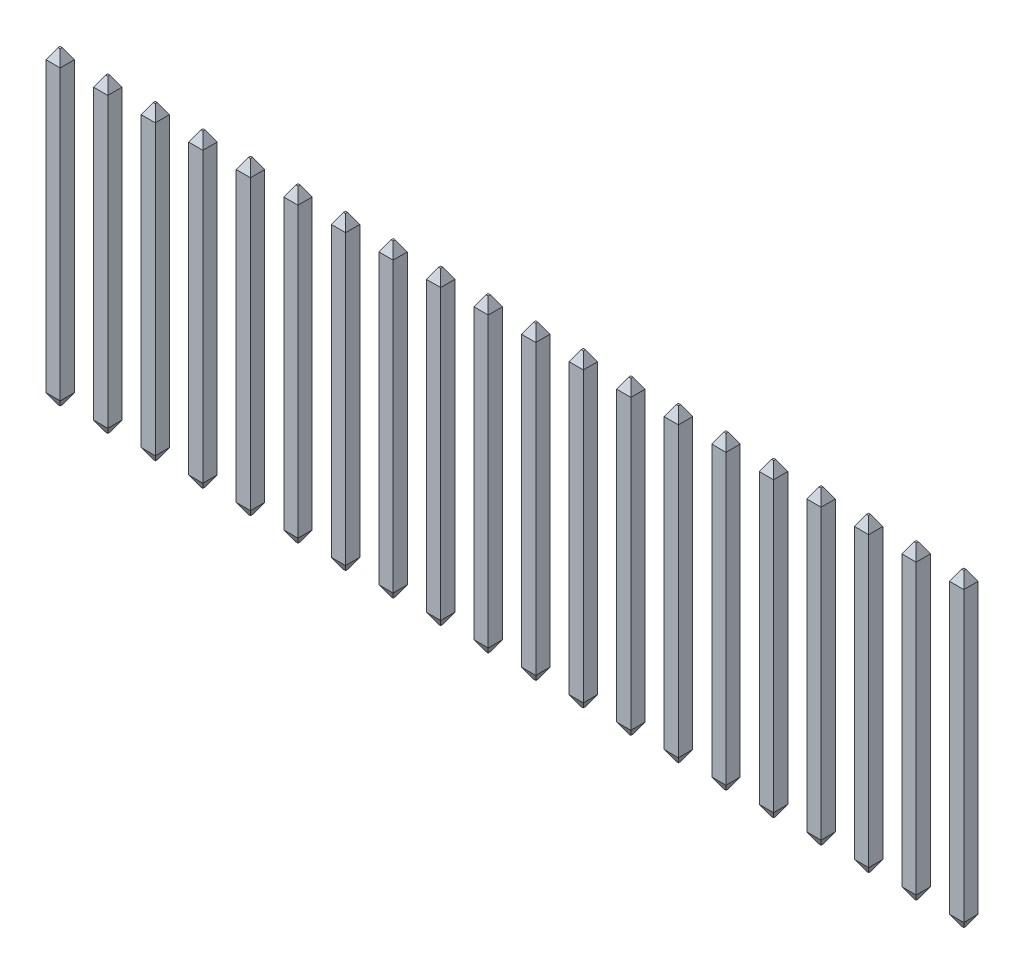
from build123d import *

# Parameters (mm, degrees)
SKETCH1_W                   = 0.38
SKETCH1_H                   = 0.38
BOSS_EXTRUDE1_DEPTH         = 5.72
BOSS_EXTRUDE1_DEPTH_BACK    = 2.54
BOSS_EXTRUDE1_2_DEPTH       = 5.72
BOSS_EXTRUDE1_2_DEPTH_BACK  = 2.54
BOSS_EXTRUDE1_3_DEPTH       = 5.72
BOSS_EXTRUDE1_3_DEPTH_BACK  = 2.54
BOSS_EXTRUDE1_4_DEPTH       = 5.72
BOSS_EXTRUDE1_4_DEPTH_BACK  = 2.54
BOSS_EXTRUDE1_5_DEPTH       = 5.72
BOSS_EXTRUDE1_5_DEPTH_BACK  = 2.54
BOSS_EXTRUDE1_6_DEPTH       = 5.72
BOSS_EXTRUDE1_6_DEPTH_BACK  = 2.54
BOSS_EXTRUDE1_7_DEPTH       = 5.72
BOSS_EXTRUDE1_7_DEPTH_BACK  = 2.54
BOSS_EXTRUDE1_8_DEPTH       = 5.72
BOSS_EXTRUDE1_8_DEPTH_BACK  = 2.54
BOSS_EXTRUDE1_9_DEPTH       = 5.72
BOSS_EXTRUDE1_9_DEPTH_BACK  = 2.54
BOSS_EXTRUDE1_10_DEPTH      = 5.72
BOSS_EXTRUDE1_10_DEPTH_BACK = 2.54
BOSS_EXTRUDE1_11_DEPTH      = 5.72
BOSS_EXTRUDE1_11_DEPTH_BACK = 2.54
BOSS_EXTRUDE1_12_DEPTH      = 5.72
BOSS_EXTRUDE1_12_DEPTH_BACK = 2.54
BOSS_EXTRUDE1_13_DEPTH      = 5.72
BOSS_EXTRUDE1_13_DEPTH_BACK = 2.54
BOSS_EXTRUDE1_14_DEPTH      = 5.72
BOSS_EXTRUDE1_14_DEPTH_BACK = 2.54
BOSS_EXTRUDE1_15_DEPTH      = 5.72
BOSS_EXTRUDE1_15_DEPTH_BACK = 2.54
BOSS_EXTRUDE1_16_DEPTH      = 5.72
BOSS_EXTRUDE1_16_DEPTH_BACK = 2.54
BOSS_EXTRUDE1_17_DEPTH      = 5.72
BOSS_EXTRUDE1_17_DEPTH_BACK = 2.54
BOSS_EXTRUDE1_18_DEPTH      = 5.72
BOSS_EXTRUDE1_18_DEPTH_BACK = 2.54
BOSS_EXTRUDE1_19_DEPTH      = 5.72
BOSS_EXTRUDE1_19_DEPTH_BACK = 2.54
BOSS_EXTRUDE1_20_DEPTH      = 5.72
BOSS_EXTRUDE1_20_DEPTH_BACK = 2.54
SKETCH2_W                   = 24.51
SKETCH2_H                   = 0.38
BOSS_EXTRUDE2_DEPTH         = 1
CHAMFER1_SIZE               = 0.28
CHAMFER1_SIZE2              = 0.161658075
CHAMFER1_PART_2_SIZE        = 0.28
CHAMFER1_PART_2_SIZE2       = 0.161658075
CHAMFER1_PART_3_SIZE        = 0.28
CHAMFER1_PART_3_SIZE2       = 0.161658075
CHAMFER1_PART_4_SIZE        = 0.28
CHAMFER1_PART_4_SIZE2       = 0.161658075
CHAMFER1_PART_5_SIZE        = 0.28
CHAMFER1_PART_5_SIZE2       = 0.161658075
CHAMFER1_PART_6_SIZE        = 0.28
CHAMFER1_PART_6_SIZE2       = 0.161658075
CHAMFER1_PART_7_SIZE        = 0.28
CHAMFER1_PART_7_SIZE2       = 0.161658075
CHAMFER1_PART_8_SIZE        = 0.28
CHAMFER1_PART_8_SIZE2       = 0.161658075
CHAMFER1_PART_9_SIZE        = 0.28
CHAMFER1_PART_9_SIZE2       = 0.161658075
CHAMFER1_PART_10_SIZE       = 0.28
CHAMFER1_PART_10_SIZE2      = 0.161658075
CHAMFER1_PART_11_SIZE       = 0.28
CHAMFER1_PART_11_SIZE2      = 0.161658075
CHAMFER1_PART_12_SIZE       = 0.28
CHAMFER1_PART_12_SIZE2      = 0.161658075
CHAMFER1_PART_13_SIZE       = 0.28
CHAMFER1_PART_13_SIZE2      = 0.161658075
CHAMFER1_PART_14_SIZE       = 0.28
CHAMFER1_PART_14_SIZE2      = 0.161658075
CHAMFER1_PART_15_SIZE       = 0.28
CHAMFER1_PART_15_SIZE2      = 0.161658075
CHAMFER1_PART_16_SIZE       = 0.28
CHAMFER1_PART_16_SIZE2      = 0.161658075
CHAMFER1_PART_17_SIZE       = 0.28
CHAMFER1_PART_17_SIZE2      = 0.161658075
CHAMFER1_PART_18_SIZE       = 0.28
CHAMFER1_PART_18_SIZE2      = 0.161658075
CHAMFER1_PART_19_SIZE       = 0.28
CHAMFER1_PART_19_SIZE2      = 0.161658075
CHAMFER1_PART_20_SIZE       = 0.28
CHAMFER1_PART_20_SIZE2      = 0.161658075
CHAMFER1_PART_21_SIZE       = 0.28
CHAMFER1_PART_21_SIZE2      = 0.161658075
CHAMFER1_PART_22_SIZE       = 0.28
CHAMFER1_PART_22_SIZE2      = 0.161658075
CHAMFER1_PART_23_SIZE       = 0.28
CHAMFER1_PART_23_SIZE2      = 0.161658075
CHAMFER1_PART_24_SIZE       = 0.28
CHAMFER1_PART_24_SIZE2      = 0.161658075
CHAMFER1_PART_25_SIZE       = 0.28
CHAMFER1_PART_25_SIZE2      = 0.161658075
CHAMFER1_PART_26_SIZE       = 0.28
CHAMFER1_PART_26_SIZE2      = 0.161658075
CHAMFER1_PART_27_SIZE       = 0.28
CHAMFER1_PART_27_SIZE2      = 0.161658075
CHAMFER1_PART_28_SIZE       = 0.28
CHAMFER1_PART_28_SIZE2      = 0.161658075
CHAMFER1_PART_29_SIZE       = 0.28
CHAMFER1_PART_29_SIZE2      = 0.161658075
CHAMFER1_PART_30_SIZE       = 0.28
CHAMFER1_PART_30_SIZE2      = 0.161658075
CHAMFER1_PART_31_SIZE       = 0.28
CHAMFER1_PART_31_SIZE2      = 0.161658075
CHAMFER1_PART_32_SIZE       = 0.28
CHAMFER1_PART_32_SIZE2      = 0.161658075
CHAMFER1_PART_33_SIZE       = 0.28
CHAMFER1_PART_33_SIZE2      = 0.161658075
CHAMFER1_PART_34_SIZE       = 0.28
CHAMFER1_PART_34_SIZE2      = 0.161658075
CHAMFER1_PART_35_SIZE       = 0.28
CHAMFER1_PART_35_SIZE2      = 0.161658075
CHAMFER1_PART_36_SIZE       = 0.28
CHAMFER1_PART_36_SIZE2      = 0.161658075
CHAMFER1_PART_37_SIZE       = 0.28
CHAMFER1_PART_37_SIZE2      = 0.161658075
CHAMFER1_PART_38_SIZE       = 0.28
CHAMFER1_PART_38_SIZE2      = 0.161658075
CHAMFER1_PART_39_SIZE       = 0.28
CHAMFER1_PART_39_SIZE2      = 0.161658075
CHAMFER1_PART_40_SIZE       = 0.28
CHAMFER1_PART_40_SIZE2      = 0.161658075
CHAMFER1_PART_41_SIZE       = 0.28
CHAMFER1_PART_41_SIZE2      = 0.161658075
CHAMFER1_PART_42_SIZE       = 0.28
CHAMFER1_PART_42_SIZE2      = 0.161658075
CHAMFER2_SIZE               = 0.28
CHAMFER2_SIZE2              = 0.161658075
CHAMFER2_PART_2_SIZE        = 0.28
CHAMFER2_PART_2_SIZE2       = 0.161658075
CHAMFER2_PART_3_SIZE        = 0.28
CHAMFER2_PART_3_SIZE2       = 0.161658075
CHAMFER2_PART_4_SIZE        = 0.28
CHAMFER2_PART_4_SIZE2       = 0.161658075
CHAMFER2_PART_5_SIZE        = 0.28
CHAMFER2_PART_5_SIZE2       = 0.161658075
CHAMFER2_PART_6_SIZE        = 0.28
CHAMFER2_PART_6_SIZE2       = 0.161658075
CHAMFER2_PART_7_SIZE        = 0.28
CHAMFER2_PART_7_SIZE2       = 0.161658075
CHAMFER2_PART_8_SIZE        = 0.28
CHAMFER2_PART_8_SIZE2       = 0.161658075
CHAMFER2_PART_9_SIZE        = 0.28
CHAMFER2_PART_9_SIZE2       = 0.161658075
CHAMFER2_PART_10_SIZE       = 0.28
CHAMFER2_PART_10_SIZE2      = 0.161658075
CHAMFER2_PART_11_SIZE       = 0.28
CHAMFER2_PART_11_SIZE2      = 0.161658075
CHAMFER2_PART_12_SIZE       = 0.28
CHAMFER2_PART_12_SIZE2      = 0.161658075
CHAMFER2_PART_13_SIZE       = 0.28
CHAMFER2_PART_13_SIZE2      = 0.161658075
CHAMFER2_PART_14_SIZE       = 0.28
CHAMFER2_PART_14_SIZE2      = 0.161658075
CHAMFER2_PART_15_SIZE       = 0.28
CHAMFER2_PART_15_SIZE2      = 0.161658075
CHAMFER2_PART_16_SIZE       = 0.28
CHAMFER2_PART_16_SIZE2      = 0.161658075
CHAMFER2_PART_17_SIZE       = 0.28
CHAMFER2_PART_17_SIZE2      = 0.161658075
CHAMFER2_PART_18_SIZE       = 0.28
CHAMFER2_PART_18_SIZE2      = 0.161658075
CHAMFER2_PART_19_SIZE       = 0.28
CHAMFER2_PART_19_SIZE2      = 0.161658075
CHAMFER2_PART_20_SIZE       = 0.28
CHAMFER2_PART_20_SIZE2      = 0.161658075
CHAMFER2_PART_21_SIZE       = 0.28
CHAMFER2_PART_21_SIZE2      = 0.161658075
CHAMFER2_PART_22_SIZE       = 0.28
CHAMFER2_PART_22_SIZE2      = 0.161658075
CHAMFER2_PART_23_SIZE       = 0.28
CHAMFER2_PART_23_SIZE2      = 0.161658075
CHAMFER2_PART_24_SIZE       = 0.28
CHAMFER2_PART_24_SIZE2      = 0.161658075
CHAMFER2_PART_25_SIZE       = 0.28
CHAMFER2_PART_25_SIZE2      = 0.161658075
CHAMFER2_PART_26_SIZE       = 0.28
CHAMFER2_PART_26_SIZE2      = 0.161658075
CHAMFER2_PART_27_SIZE       = 0.28
CHAMFER2_PART_27_SIZE2      = 0.161658075
CHAMFER2_PART_28_SIZE       = 0.28
CHAMFER2_PART_28_SIZE2      = 0.161658075
CHAMFER2_PART_29_SIZE       = 0.28
CHAMFER2_PART_29_SIZE2      = 0.161658075
CHAMFER2_PART_30_SIZE       = 0.28
CHAMFER2_PART_30_SIZE2      = 0.161658075
CHAMFER2_PART_31_SIZE       = 0.28
CHAMFER2_PART_31_SIZE2      = 0.161658075
CHAMFER2_PART_32_SIZE       = 0.28
CHAMFER2_PART_32_SIZE2      = 0.161658075
CHAMFER2_PART_33_SIZE       = 0.28
CHAMFER2_PART_33_SIZE2      = 0.161658075
CHAMFER2_PART_34_SIZE       = 0.28
CHAMFER2_PART_34_SIZE2      = 0.161658075
CHAMFER2_PART_35_SIZE       = 0.28
CHAMFER2_PART_35_SIZE2      = 0.161658075
CHAMFER2_PART_36_SIZE       = 0.28
CHAMFER2_PART_36_SIZE2      = 0.161658075
CHAMFER2_PART_37_SIZE       = 0.28
CHAMFER2_PART_37_SIZE2      = 0.161658075
CHAMFER2_PART_38_SIZE       = 0.28
CHAMFER2_PART_38_SIZE2      = 0.161658075
CHAMFER2_PART_39_SIZE       = 0.28
CHAMFER2_PART_39_SIZE2      = 0.161658075
CHAMFER2_PART_40_SIZE       = 0.28
CHAMFER2_PART_40_SIZE2      = 0.161658075
CHAMFER2_PART_41_SIZE       = 0.28
CHAMFER2_PART_41_SIZE2      = 0.161658075
CHAMFER2_PART_42_SIZE       = 0.28
CHAMFER2_PART_42_SIZE2      = 0.161658075
SKETCH3_W                   = 0.89
SKETCH3_H                   = 0.38
CUT_EXTRUDE1_DEPTH          = 1


with BuildPart() as part:
    # Sketch1 → Boss-Extrude1 (new body, two sides)
    with BuildSketch(Plane(origin=(0, 0, 0), x_dir=(1, 0, 0), z_dir=(0, 1, 0))) as boss_extrude1_sk:
        with Locations((-10.795, 0)):
            Rectangle(SKETCH1_W, SKETCH1_H)
    extrude(amount=BOSS_EXTRUDE1_DEPTH)
    extrude(boss_extrude1_sk.sketch, amount=-BOSS_EXTRUDE1_DEPTH_BACK)



with BuildPart() as body_2:
    # Sketch1 → Boss-Extrude1 2 (new body, two sides)
    with BuildSketch(Plane(origin=(0, 0, 0), x_dir=(1, 0, 0), z_dir=(0, 1, 0))) as boss_extrude1_2_sk:
        with Locations((-12.065, 0)):
            Rectangle(SKETCH1_W, SKETCH1_H)
    extrude(amount=BOSS_EXTRUDE1_2_DEPTH)
    extrude(boss_extrude1_2_sk.sketch, amount=-BOSS_EXTRUDE1_2_DEPTH_BACK)


with BuildPart() as body_3:
    # Sketch1 → Boss-Extrude1 3 (new body, two sides)
    with BuildSketch(Plane(origin=(0, 0, 0), x_dir=(1, 0, 0), z_dir=(0, 1, 0))) as boss_extrude1_3_sk:
        with Locations((-9.525, 0)):
            Rectangle(SKETCH1_W, SKETCH1_H)
    extrude(amount=BOSS_EXTRUDE1_3_DEPTH)
    extrude(boss_extrude1_3_sk.sketch, amount=-BOSS_EXTRUDE1_3_DEPTH_BACK)


with BuildPart() as body_4:
    # Sketch1 → Boss-Extrude1 4 (new body, two sides)
    with BuildSketch(Plane(origin=(0, 0, 0), x_dir=(1, 0, 0), z_dir=(0, 1, 0))) as boss_extrude1_4_sk:
        with Locations((-8.255, 0)):
            Rectangle(SKETCH1_W, SKETCH1_H)
    extrude(amount=BOSS_EXTRUDE1_4_DEPTH)
    extrude(boss_extrude1_4_sk.sketch, amount=-BOSS_EXTRUDE1_4_DEPTH_BACK)


with BuildPart() as body_5:
    # Sketch1 → Boss-Extrude1 5 (new body, two sides)
    with BuildSketch(Plane(origin=(0, 0, 0), x_dir=(1, 0, 0), z_dir=(0, 1, 0))) as boss_extrude1_5_sk:
        with Locations((-6.985, 0)):
            Rectangle(SKETCH1_W, SKETCH1_H)
    extrude(amount=BOSS_EXTRUDE1_5_DEPTH)
    extrude(boss_extrude1_5_sk.sketch, amount=-BOSS_EXTRUDE1_5_DEPTH_BACK)


with BuildPart() as body_6:
    # Sketch1 → Boss-Extrude1 6 (new body, two sides)
    with BuildSketch(Plane(origin=(0, 0, 0), x_dir=(1, 0, 0), z_dir=(0, 1, 0))) as boss_extrude1_6_sk:
        with Locations((-5.715, 0)):
            Rectangle(SKETCH1_W, SKETCH1_H)
    extrude(amount=BOSS_EXTRUDE1_6_DEPTH)
    extrude(boss_extrude1_6_sk.sketch, amount=-BOSS_EXTRUDE1_6_DEPTH_BACK)


with BuildPart() as body_7:
    # Sketch1 → Boss-Extrude1 7 (new body, two sides)
    with BuildSketch(Plane(origin=(0, 0, 0), x_dir=(1, 0, 0), z_dir=(0, 1, 0))) as boss_extrude1_7_sk:
        with Locations((-4.445, 0)):
            Rectangle(SKETCH1_W, SKETCH1_H)
    extrude(amount=BOSS_EXTRUDE1_7_DEPTH)
    extrude(boss_extrude1_7_sk.sketch, amount=-BOSS_EXTRUDE1_7_DEPTH_BACK)


with BuildPart() as body_8:
    # Sketch1 → Boss-Extrude1 8 (new body, two sides)
    with BuildSketch(Plane(origin=(0, 0, 0), x_dir=(1, 0, 0), z_dir=(0, 1, 0))) as boss_extrude1_8_sk:
        with Locations((-3.175, 0)):
            Rectangle(SKETCH1_W, SKETCH1_H)
    extrude(amount=BOSS_EXTRUDE1_8_DEPTH)
    extrude(boss_extrude1_8_sk.sketch, amount=-BOSS_EXTRUDE1_8_DEPTH_BACK)


with BuildPart() as body_9:
    # Sketch1 → Boss-Extrude1 9 (new body, two sides)
    with BuildSketch(Plane(origin=(0, 0, 0), x_dir=(1, 0, 0), z_dir=(0, 1, 0))) as boss_extrude1_9_sk:
        with Locations((-1.905, 0)):
            Rectangle(SKETCH1_W, SKETCH1_H)
    extrude(amount=BOSS_EXTRUDE1_9_DEPTH)
    extrude(boss_extrude1_9_sk.sketch, amount=-BOSS_EXTRUDE1_9_DEPTH_BACK)


with BuildPart() as body_10:
    # Sketch1 → Boss-Extrude1 10 (new body, two sides)
    with BuildSketch(Plane(origin=(0, 0, 0), x_dir=(1, 0, 0), z_dir=(0, 1, 0))) as boss_extrude1_10_sk:
        with Locations((-0.635, 0)):
            Rectangle(SKETCH1_W, SKETCH1_H)
    extrude(amount=BOSS_EXTRUDE1_10_DEPTH)
    extrude(boss_extrude1_10_sk.sketch, amount=-BOSS_EXTRUDE1_10_DEPTH_BACK)


with BuildPart() as body_11:
    # Sketch1 → Boss-Extrude1 11 (new body, two sides)
    with BuildSketch(Plane(origin=(0, 0, 0), x_dir=(1, 0, 0), z_dir=(0, 1, 0))) as boss_extrude1_11_sk:
        with Locations((0.635, 0)):
            Rectangle(SKETCH1_W, SKETCH1_H)
    extrude(amount=BOSS_EXTRUDE1_11_DEPTH)
    extrude(boss_extrude1_11_sk.sketch, amount=-BOSS_EXTRUDE1_11_DEPTH_BACK)


with BuildPart() as body_12:
    # Sketch1 → Boss-Extrude1 12 (new body, two sides)
    with BuildSketch(Plane(origin=(0, 0, 0), x_dir=(1, 0, 0), z_dir=(0, 1, 0))) as boss_extrude1_12_sk:
        with Locations((1.905, 0)):
            Rectangle(SKETCH1_W, SKETCH1_H)
    extrude(amount=BOSS_EXTRUDE1_12_DEPTH)
    extrude(boss_extrude1_12_sk.sketch, amount=-BOSS_EXTRUDE1_12_DEPTH_BACK)


with BuildPart() as body_13:
    # Sketch1 → Boss-Extrude1 13 (new body, two sides)
    with BuildSketch(Plane(origin=(0, 0, 0), x_dir=(1, 0, 0), z_dir=(0, 1, 0))) as boss_extrude1_13_sk:
        with Locations((3.175, 0)):
            Rectangle(SKETCH1_W, SKETCH1_H)
    extrude(amount=BOSS_EXTRUDE1_13_DEPTH)
    extrude(boss_extrude1_13_sk.sketch, amount=-BOSS_EXTRUDE1_13_DEPTH_BACK)


with BuildPart() as body_14:
    # Sketch1 → Boss-Extrude1 14 (new body, two sides)
    with BuildSketch(Plane(origin=(0, 0, 0), x_dir=(1, 0, 0), z_dir=(0, 1, 0))) as boss_extrude1_14_sk:
        with Locations((4.445, 0)):
            Rectangle(SKETCH1_W, SKETCH1_H)
    extrude(amount=BOSS_EXTRUDE1_14_DEPTH)
    extrude(boss_extrude1_14_sk.sketch, amount=-BOSS_EXTRUDE1_14_DEPTH_BACK)


with BuildPart() as body_15:
    # Sketch1 → Boss-Extrude1 15 (new body, two sides)
    with BuildSketch(Plane(origin=(0, 0, 0), x_dir=(1, 0, 0), z_dir=(0, 1, 0))) as boss_extrude1_15_sk:
        with Locations((5.715, 0)):
            Rectangle(SKETCH1_W, SKETCH1_H)
    extrude(amount=BOSS_EXTRUDE1_15_DEPTH)
    extrude(boss_extrude1_15_sk.sketch, amount=-BOSS_EXTRUDE1_15_DEPTH_BACK)


with BuildPart() as body_16:
    # Sketch1 → Boss-Extrude1 16 (new body, two sides)
    with BuildSketch(Plane(origin=(0, 0, 0), x_dir=(1, 0, 0), z_dir=(0, 1, 0))) as boss_extrude1_16_sk:
        with Locations((6.985, 0)):
            Rectangle(SKETCH1_W, SKETCH1_H)
    extrude(amount=BOSS_EXTRUDE1_16_DEPTH)
    extrude(boss_extrude1_16_sk.sketch, amount=-BOSS_EXTRUDE1_16_DEPTH_BACK)


with BuildPart() as body_17:
    # Sketch1 → Boss-Extrude1 17 (new body, two sides)
    with BuildSketch(Plane(origin=(0, 0, 0), x_dir=(1, 0, 0), z_dir=(0, 1, 0))) as boss_extrude1_17_sk:
        with Locations((8.255, 0)):
            Rectangle(SKETCH1_W, SKETCH1_H)
    extrude(amount=BOSS_EXTRUDE1_17_DEPTH)
    extrude(boss_extrude1_17_sk.sketch, amount=-BOSS_EXTRUDE1_17_DEPTH_BACK)


with BuildPart() as body_18:
    # Sketch1 → Boss-Extrude1 18 (new body, two sides)
    with BuildSketch(Plane(origin=(0, 0, 0), x_dir=(1, 0, 0), z_dir=(0, 1, 0))) as boss_extrude1_18_sk:
        with Locations((9.525, 0)):
            Rectangle(SKETCH1_W, SKETCH1_H)
    extrude(amount=BOSS_EXTRUDE1_18_DEPTH)
    extrude(boss_extrude1_18_sk.sketch, amount=-BOSS_EXTRUDE1_18_DEPTH_BACK)


with BuildPart() as body_19:
    # Sketch1 → Boss-Extrude1 19 (new body, two sides)
    with BuildSketch(Plane(origin=(0, 0, 0), x_dir=(1, 0, 0), z_dir=(0, 1, 0))) as boss_extrude1_19_sk:
        with Locations((10.795, 0)):
            Rectangle(SKETCH1_W, SKETCH1_H)
    extrude(amount=BOSS_EXTRUDE1_19_DEPTH)
    extrude(boss_extrude1_19_sk.sketch, amount=-BOSS_EXTRUDE1_19_DEPTH_BACK)


with BuildPart() as body_20:
    # Sketch1 → Boss-Extrude1 20 (new body, two sides)
    with BuildSketch(Plane(origin=(0, 0, 0), x_dir=(1, 0, 0), z_dir=(0, 1, 0))) as boss_extrude1_20_sk:
        with Locations((12.065, 0)):
            Rectangle(SKETCH1_W, SKETCH1_H)
    extrude(amount=BOSS_EXTRUDE1_20_DEPTH)
    extrude(boss_extrude1_20_sk.sketch, amount=-BOSS_EXTRUDE1_20_DEPTH_BACK)


with BuildPart() as part_1:
    add(part.part)

    add(body_2.part)  # Boss-Extrude2 merges body 2

    add(body_3.part)  # Boss-Extrude2 merges body 3

    add(body_4.part)  # Boss-Extrude2 merges body 4

    add(body_5.part)  # Boss-Extrude2 merges body 5

    add(body_6.part)  # Boss-Extrude2 merges body 6

    add(body_7.part)  # Boss-Extrude2 merges body 7

    add(body_8.part)  # Boss-Extrude2 merges body 8

    add(body_9.part)  # Boss-Extrude2 merges body 9

    add(body_10.part)  # Boss-Extrude2 merges body 10

    add(body_11.part)  # Boss-Extrude2 merges body 11

    add(body_12.part)  # Boss-Extrude2 merges body 12

    add(body_13.part)  # Boss-Extrude2 merges body 13

    add(body_14.part)  # Boss-Extrude2 merges body 14

    add(body_15.part)  # Boss-Extrude2 merges body 15

    add(body_16.part)  # Boss-Extrude2 merges body 16

    add(body_17.part)  # Boss-Extrude2 merges body 17

    add(body_18.part)  # Boss-Extrude2 merges body 18

    add(body_19.part)  # Boss-Extrude2 merges body 19

    add(body_20.part)  # Boss-Extrude2 merges body 20
    # Sketch2 → Boss-Extrude2 (add)
    with BuildSketch(Plane(origin=(0, 0, 0), x_dir=(1, 0, 0), z_dir=(0, 1, 0))):
        Rectangle(SKETCH2_W, SKETCH2_H)
    extrude(amount=BOSS_EXTRUDE2_DEPTH)

    # Chamfer1
    chamfer1_edges = [part_1.edges().sort_by_distance(p)[0] for p in [
        (-8.255, 5.72, -0.19),
        (-6.985, 5.72, -0.19),
        (-12.065, 5.72, -0.19),
        (-5.715, 5.72, -0.19),
        (-4.445, 5.72, -0.19),
        (-3.175, 5.72, -0.19),
        (-1.905, 5.72, -0.19),
        (-0.635, 5.72, -0.19),
        (0.635, 5.72, -0.19),
        (1.905, 5.72, -0.19),
        (3.175, 5.72, -0.19),
        (4.445, 5.72, -0.19),
        (5.715, 5.72, -0.19),
        (6.985, 5.72, -0.19),
        (8.255, 5.72, -0.19),
        (9.525, 5.72, -0.19),
        (10.795, 5.72, -0.19),
        (12.065, 5.72, -0.19),
        (-10.795, 5.72, -0.19),
        (-9.525, 5.72, -0.19),
    ]]
    chamfer1_side = [part_1.faces().sort_by_distance(p)[0] for p in [
        (12.065, 5.461355901, -0.19),
    ]]
    chamfer(chamfer1_edges, length=CHAMFER1_SIZE, length2=CHAMFER1_SIZE2, reference=chamfer1_side[0])

    # Chamfer1 part 2
    chamfer1_part_2_edges = [part_1.edges().sort_by_distance(p)[0] for p in [
        (-8.445, 5.72, 0),
    ]]
    chamfer1_part_2_side = [part_1.faces().sort_by_distance(p)[0] for p in [
        (-8.445, 3.36, 0),
    ]]
    chamfer(chamfer1_part_2_edges, length=CHAMFER1_PART_2_SIZE, length2=CHAMFER1_PART_2_SIZE2, reference=chamfer1_part_2_side[0])

    # Chamfer1 part 3
    chamfer1_part_3_edges = [part_1.edges().sort_by_distance(p)[0] for p in [
        (-8.255, 5.72, 0.19),
        (-6.985, 5.72, 0.19),
        (-12.065, 5.72, 0.19),
        (-5.715, 5.72, 0.19),
        (-4.445, 5.72, 0.19),
        (-3.175, 5.72, 0.19),
        (-1.905, 5.72, 0.19),
        (-0.635, 5.72, 0.19),
        (0.635, 5.72, 0.19),
        (1.905, 5.72, 0.19),
        (3.175, 5.72, 0.19),
        (4.445, 5.72, 0.19),
        (5.715, 5.72, 0.19),
        (6.985, 5.72, 0.19),
        (8.255, 5.72, 0.19),
        (9.525, 5.72, 0.19),
        (10.795, 5.72, 0.19),
        (12.065, 5.72, 0.19),
        (-10.795, 5.72, 0.19),
        (-9.525, 5.72, 0.19),
    ]]
    chamfer1_part_3_side = [part_1.faces().sort_by_distance(p)[0] for p in [
        (12.133644099, 3.36, 0.19),
    ]]
    chamfer(chamfer1_part_3_edges, length=CHAMFER1_PART_3_SIZE, length2=CHAMFER1_PART_3_SIZE2, reference=chamfer1_part_3_side[0])

    # Chamfer1 part 4
    chamfer1_part_4_edges = [part_1.edges().sort_by_distance(p)[0] for p in [
        (-8.065, 5.72, 0),
    ]]
    chamfer1_part_4_side = [part_1.faces().sort_by_distance(p)[0] for p in [
        (-8.065, 3.36, 0),
    ]]
    chamfer(chamfer1_part_4_edges, length=CHAMFER1_PART_4_SIZE, length2=CHAMFER1_PART_4_SIZE2, reference=chamfer1_part_4_side[0])

    # Chamfer1 part 5
    chamfer1_part_5_edges = [part_1.edges().sort_by_distance(p)[0] for p in [
        (-7.175, 5.72, 0),
    ]]
    chamfer1_part_5_side = [part_1.faces().sort_by_distance(p)[0] for p in [
        (-7.175, 3.36, 0),
    ]]
    chamfer(chamfer1_part_5_edges, length=CHAMFER1_PART_5_SIZE, length2=CHAMFER1_PART_5_SIZE2, reference=chamfer1_part_5_side[0])

    # Chamfer1 part 6
    chamfer1_part_6_edges = [part_1.edges().sort_by_distance(p)[0] for p in [
        (-6.795, 5.72, 0),
    ]]
    chamfer1_part_6_side = [part_1.faces().sort_by_distance(p)[0] for p in [
        (-6.795, 3.36, 0),
    ]]
    chamfer(chamfer1_part_6_edges, length=CHAMFER1_PART_6_SIZE, length2=CHAMFER1_PART_6_SIZE2, reference=chamfer1_part_6_side[0])

    # Chamfer1 part 7
    chamfer1_part_7_edges = [part_1.edges().sort_by_distance(p)[0] for p in [
        (-11.875, 5.72, 0),
    ]]
    chamfer1_part_7_side = [part_1.faces().sort_by_distance(p)[0] for p in [
        (-11.875, 3.36, 0),
    ]]
    chamfer(chamfer1_part_7_edges, length=CHAMFER1_PART_7_SIZE, length2=CHAMFER1_PART_7_SIZE2, reference=chamfer1_part_7_side[0])

    # Chamfer1 part 8
    chamfer1_part_8_edges = [part_1.edges().sort_by_distance(p)[0] for p in [
        (-12.255, 5.72, 0),
    ]]
    chamfer1_part_8_side = [part_1.faces().sort_by_distance(p)[0] for p in [
        (-12.255, 1.59, 0),
    ]]
    chamfer(chamfer1_part_8_edges, length=CHAMFER1_PART_8_SIZE, length2=CHAMFER1_PART_8_SIZE2, reference=chamfer1_part_8_side[0])

    # Chamfer1 part 9
    chamfer1_part_9_edges = [part_1.edges().sort_by_distance(p)[0] for p in [
        (-5.905, 5.72, 0),
    ]]
    chamfer1_part_9_side = [part_1.faces().sort_by_distance(p)[0] for p in [
        (-5.905, 3.36, 0),
    ]]
    chamfer(chamfer1_part_9_edges, length=CHAMFER1_PART_9_SIZE, length2=CHAMFER1_PART_9_SIZE2, reference=chamfer1_part_9_side[0])

    # Chamfer1 part 10
    chamfer1_part_10_edges = [part_1.edges().sort_by_distance(p)[0] for p in [
        (-5.525, 5.72, 0),
    ]]
    chamfer1_part_10_side = [part_1.faces().sort_by_distance(p)[0] for p in [
        (-5.525, 3.36, 0),
    ]]
    chamfer(chamfer1_part_10_edges, length=CHAMFER1_PART_10_SIZE, length2=CHAMFER1_PART_10_SIZE2, reference=chamfer1_part_10_side[0])

    # Chamfer1 part 11
    chamfer1_part_11_edges = [part_1.edges().sort_by_distance(p)[0] for p in [
        (-4.635, 5.72, 0),
    ]]
    chamfer1_part_11_side = [part_1.faces().sort_by_distance(p)[0] for p in [
        (-4.635, 3.36, 0),
    ]]
    chamfer(chamfer1_part_11_edges, length=CHAMFER1_PART_11_SIZE, length2=CHAMFER1_PART_11_SIZE2, reference=chamfer1_part_11_side[0])

    # Chamfer1 part 12
    chamfer1_part_12_edges = [part_1.edges().sort_by_distance(p)[0] for p in [
        (-4.255, 5.72, 0),
    ]]
    chamfer1_part_12_side = [part_1.faces().sort_by_distance(p)[0] for p in [
        (-4.255, 3.36, 0),
    ]]
    chamfer(chamfer1_part_12_edges, length=CHAMFER1_PART_12_SIZE, length2=CHAMFER1_PART_12_SIZE2, reference=chamfer1_part_12_side[0])

    # Chamfer1 part 13
    chamfer1_part_13_edges = [part_1.edges().sort_by_distance(p)[0] for p in [
        (-3.365, 5.72, 0),
    ]]
    chamfer1_part_13_side = [part_1.faces().sort_by_distance(p)[0] for p in [
        (-3.365, 3.36, 0),
    ]]
    chamfer(chamfer1_part_13_edges, length=CHAMFER1_PART_13_SIZE, length2=CHAMFER1_PART_13_SIZE2, reference=chamfer1_part_13_side[0])

    # Chamfer1 part 14
    chamfer1_part_14_edges = [part_1.edges().sort_by_distance(p)[0] for p in [
        (-2.985, 5.72, 0),
    ]]
    chamfer1_part_14_side = [part_1.faces().sort_by_distance(p)[0] for p in [
        (-2.985, 3.36, 0),
    ]]
    chamfer(chamfer1_part_14_edges, length=CHAMFER1_PART_14_SIZE, length2=CHAMFER1_PART_14_SIZE2, reference=chamfer1_part_14_side[0])

    # Chamfer1 part 15
    chamfer1_part_15_edges = [part_1.edges().sort_by_distance(p)[0] for p in [
        (-2.095, 5.72, 0),
    ]]
    chamfer1_part_15_side = [part_1.faces().sort_by_distance(p)[0] for p in [
        (-2.095, 3.36, 0),
    ]]
    chamfer(chamfer1_part_15_edges, length=CHAMFER1_PART_15_SIZE, length2=CHAMFER1_PART_15_SIZE2, reference=chamfer1_part_15_side[0])

    # Chamfer1 part 16
    chamfer1_part_16_edges = [part_1.edges().sort_by_distance(p)[0] for p in [
        (-1.715, 5.72, 0),
    ]]
    chamfer1_part_16_side = [part_1.faces().sort_by_distance(p)[0] for p in [
        (-1.715, 3.36, 0),
    ]]
    chamfer(chamfer1_part_16_edges, length=CHAMFER1_PART_16_SIZE, length2=CHAMFER1_PART_16_SIZE2, reference=chamfer1_part_16_side[0])

    # Chamfer1 part 17
    chamfer1_part_17_edges = [part_1.edges().sort_by_distance(p)[0] for p in [
        (-0.825, 5.72, 0),
    ]]
    chamfer1_part_17_side = [part_1.faces().sort_by_distance(p)[0] for p in [
        (-0.825, 3.36, 0),
    ]]
    chamfer(chamfer1_part_17_edges, length=CHAMFER1_PART_17_SIZE, length2=CHAMFER1_PART_17_SIZE2, reference=chamfer1_part_17_side[0])

    # Chamfer1 part 18
    chamfer1_part_18_edges = [part_1.edges().sort_by_distance(p)[0] for p in [
        (-0.445, 5.72, 0),
    ]]
    chamfer1_part_18_side = [part_1.faces().sort_by_distance(p)[0] for p in [
        (-0.445, 3.36, 0),
    ]]
    chamfer(chamfer1_part_18_edges, length=CHAMFER1_PART_18_SIZE, length2=CHAMFER1_PART_18_SIZE2, reference=chamfer1_part_18_side[0])

    # Chamfer1 part 19
    chamfer1_part_19_edges = [part_1.edges().sort_by_distance(p)[0] for p in [
        (0.445, 5.72, 0),
    ]]
    chamfer1_part_19_side = [part_1.faces().sort_by_distance(p)[0] for p in [
        (0.445, 3.36, 0),
    ]]
    chamfer(chamfer1_part_19_edges, length=CHAMFER1_PART_19_SIZE, length2=CHAMFER1_PART_19_SIZE2, reference=chamfer1_part_19_side[0])

    # Chamfer1 part 20
    chamfer1_part_20_edges = [part_1.edges().sort_by_distance(p)[0] for p in [
        (0.825, 5.72, 0),
    ]]
    chamfer1_part_20_side = [part_1.faces().sort_by_distance(p)[0] for p in [
        (0.825, 3.36, 0),
    ]]
    chamfer(chamfer1_part_20_edges, length=CHAMFER1_PART_20_SIZE, length2=CHAMFER1_PART_20_SIZE2, reference=chamfer1_part_20_side[0])

    # Chamfer1 part 21
    chamfer1_part_21_edges = [part_1.edges().sort_by_distance(p)[0] for p in [
        (1.715, 5.72, 0),
    ]]
    chamfer1_part_21_side = [part_1.faces().sort_by_distance(p)[0] for p in [
        (1.715, 3.36, 0),
    ]]
    chamfer(chamfer1_part_21_edges, length=CHAMFER1_PART_21_SIZE, length2=CHAMFER1_PART_21_SIZE2, reference=chamfer1_part_21_side[0])

    # Chamfer1 part 22
    chamfer1_part_22_edges = [part_1.edges().sort_by_distance(p)[0] for p in [
        (2.095, 5.72, 0),
    ]]
    chamfer1_part_22_side = [part_1.faces().sort_by_distance(p)[0] for p in [
        (2.095, 3.36, 0),
    ]]
    chamfer(chamfer1_part_22_edges, length=CHAMFER1_PART_22_SIZE, length2=CHAMFER1_PART_22_SIZE2, reference=chamfer1_part_22_side[0])

    # Chamfer1 part 23
    chamfer1_part_23_edges = [part_1.edges().sort_by_distance(p)[0] for p in [
        (2.985, 5.72, 0),
    ]]
    chamfer1_part_23_side = [part_1.faces().sort_by_distance(p)[0] for p in [
        (2.985, 3.36, 0),
    ]]
    chamfer(chamfer1_part_23_edges, length=CHAMFER1_PART_23_SIZE, length2=CHAMFER1_PART_23_SIZE2, reference=chamfer1_part_23_side[0])

    # Chamfer1 part 24
    chamfer1_part_24_edges = [part_1.edges().sort_by_distance(p)[0] for p in [
        (3.365, 5.72, 0),
    ]]
    chamfer1_part_24_side = [part_1.faces().sort_by_distance(p)[0] for p in [
        (3.365, 3.36, 0),
    ]]
    chamfer(chamfer1_part_24_edges, length=CHAMFER1_PART_24_SIZE, length2=CHAMFER1_PART_24_SIZE2, reference=chamfer1_part_24_side[0])

    # Chamfer1 part 25
    chamfer1_part_25_edges = [part_1.edges().sort_by_distance(p)[0] for p in [
        (4.255, 5.72, 0),
    ]]
    chamfer1_part_25_side = [part_1.faces().sort_by_distance(p)[0] for p in [
        (4.255, 3.36, 0),
    ]]
    chamfer(chamfer1_part_25_edges, length=CHAMFER1_PART_25_SIZE, length2=CHAMFER1_PART_25_SIZE2, reference=chamfer1_part_25_side[0])

    # Chamfer1 part 26
    chamfer1_part_26_edges = [part_1.edges().sort_by_distance(p)[0] for p in [
        (4.635, 5.72, 0),
    ]]
    chamfer1_part_26_side = [part_1.faces().sort_by_distance(p)[0] for p in [
        (4.635, 3.36, 0),
    ]]
    chamfer(chamfer1_part_26_edges, length=CHAMFER1_PART_26_SIZE, length2=CHAMFER1_PART_26_SIZE2, reference=chamfer1_part_26_side[0])

    # Chamfer1 part 27
    chamfer1_part_27_edges = [part_1.edges().sort_by_distance(p)[0] for p in [
        (5.525, 5.72, 0),
    ]]
    chamfer1_part_27_side = [part_1.faces().sort_by_distance(p)[0] for p in [
        (5.525, 3.36, 0),
    ]]
    chamfer(chamfer1_part_27_edges, length=CHAMFER1_PART_27_SIZE, length2=CHAMFER1_PART_27_SIZE2, reference=chamfer1_part_27_side[0])

    # Chamfer1 part 28
    chamfer1_part_28_edges = [part_1.edges().sort_by_distance(p)[0] for p in [
        (5.905, 5.72, 0),
    ]]
    chamfer1_part_28_side = [part_1.faces().sort_by_distance(p)[0] for p in [
        (5.905, 3.36, 0),
    ]]
    chamfer(chamfer1_part_28_edges, length=CHAMFER1_PART_28_SIZE, length2=CHAMFER1_PART_28_SIZE2, reference=chamfer1_part_28_side[0])

    # Chamfer1 part 29
    chamfer1_part_29_edges = [part_1.edges().sort_by_distance(p)[0] for p in [
        (6.795, 5.72, 0),
    ]]
    chamfer1_part_29_side = [part_1.faces().sort_by_distance(p)[0] for p in [
        (6.795, 3.36, 0),
    ]]
    chamfer(chamfer1_part_29_edges, length=CHAMFER1_PART_29_SIZE, length2=CHAMFER1_PART_29_SIZE2, reference=chamfer1_part_29_side[0])

    # Chamfer1 part 30
    chamfer1_part_30_edges = [part_1.edges().sort_by_distance(p)[0] for p in [
        (7.175, 5.72, 0),
    ]]
    chamfer1_part_30_side = [part_1.faces().sort_by_distance(p)[0] for p in [
        (7.175, 3.36, 0),
    ]]
    chamfer(chamfer1_part_30_edges, length=CHAMFER1_PART_30_SIZE, length2=CHAMFER1_PART_30_SIZE2, reference=chamfer1_part_30_side[0])

    # Chamfer1 part 31
    chamfer1_part_31_edges = [part_1.edges().sort_by_distance(p)[0] for p in [
        (8.065, 5.72, 0),
    ]]
    chamfer1_part_31_side = [part_1.faces().sort_by_distance(p)[0] for p in [
        (8.065, 3.36, 0),
    ]]
    chamfer(chamfer1_part_31_edges, length=CHAMFER1_PART_31_SIZE, length2=CHAMFER1_PART_31_SIZE2, reference=chamfer1_part_31_side[0])

    # Chamfer1 part 32
    chamfer1_part_32_edges = [part_1.edges().sort_by_distance(p)[0] for p in [
        (8.445, 5.72, 0),
    ]]
    chamfer1_part_32_side = [part_1.faces().sort_by_distance(p)[0] for p in [
        (8.445, 3.36, 0),
    ]]
    chamfer(chamfer1_part_32_edges, length=CHAMFER1_PART_32_SIZE, length2=CHAMFER1_PART_32_SIZE2, reference=chamfer1_part_32_side[0])

    # Chamfer1 part 33
    chamfer1_part_33_edges = [part_1.edges().sort_by_distance(p)[0] for p in [
        (9.335, 5.72, 0),
    ]]
    chamfer1_part_33_side = [part_1.faces().sort_by_distance(p)[0] for p in [
        (9.335, 3.36, 0),
    ]]
    chamfer(chamfer1_part_33_edges, length=CHAMFER1_PART_33_SIZE, length2=CHAMFER1_PART_33_SIZE2, reference=chamfer1_part_33_side[0])

    # Chamfer1 part 34
    chamfer1_part_34_edges = [part_1.edges().sort_by_distance(p)[0] for p in [
        (9.715, 5.72, 0),
    ]]
    chamfer1_part_34_side = [part_1.faces().sort_by_distance(p)[0] for p in [
        (9.715, 3.36, 0),
    ]]
    chamfer(chamfer1_part_34_edges, length=CHAMFER1_PART_34_SIZE, length2=CHAMFER1_PART_34_SIZE2, reference=chamfer1_part_34_side[0])

    # Chamfer1 part 35
    chamfer1_part_35_edges = [part_1.edges().sort_by_distance(p)[0] for p in [
        (10.605, 5.72, 0),
    ]]
    chamfer1_part_35_side = [part_1.faces().sort_by_distance(p)[0] for p in [
        (10.605, 3.36, 0),
    ]]
    chamfer(chamfer1_part_35_edges, length=CHAMFER1_PART_35_SIZE, length2=CHAMFER1_PART_35_SIZE2, reference=chamfer1_part_35_side[0])

    # Chamfer1 part 36
    chamfer1_part_36_edges = [part_1.edges().sort_by_distance(p)[0] for p in [
        (10.985, 5.72, 0),
    ]]
    chamfer1_part_36_side = [part_1.faces().sort_by_distance(p)[0] for p in [
        (10.985, 3.36, 0),
    ]]
    chamfer(chamfer1_part_36_edges, length=CHAMFER1_PART_36_SIZE, length2=CHAMFER1_PART_36_SIZE2, reference=chamfer1_part_36_side[0])

    # Chamfer1 part 37
    chamfer1_part_37_edges = [part_1.edges().sort_by_distance(p)[0] for p in [
        (11.875, 5.72, 0),
    ]]
    chamfer1_part_37_side = [part_1.faces().sort_by_distance(p)[0] for p in [
        (11.875, 3.36, 0),
    ]]
    chamfer(chamfer1_part_37_edges, length=CHAMFER1_PART_37_SIZE, length2=CHAMFER1_PART_37_SIZE2, reference=chamfer1_part_37_side[0])

    # Chamfer1 part 38
    chamfer1_part_38_edges = [part_1.edges().sort_by_distance(p)[0] for p in [
        (12.255, 5.72, 0),
    ]]
    chamfer1_part_38_side = [part_1.faces().sort_by_distance(p)[0] for p in [
        (12.255, 1.59, 0),
    ]]
    chamfer(chamfer1_part_38_edges, length=CHAMFER1_PART_38_SIZE, length2=CHAMFER1_PART_38_SIZE2, reference=chamfer1_part_38_side[0])

    # Chamfer1 part 39
    chamfer1_part_39_edges = [part_1.edges().sort_by_distance(p)[0] for p in [
        (-10.985, 5.72, 0),
    ]]
    chamfer1_part_39_side = [part_1.faces().sort_by_distance(p)[0] for p in [
        (-10.985, 3.36, 0),
    ]]
    chamfer(chamfer1_part_39_edges, length=CHAMFER1_PART_39_SIZE, length2=CHAMFER1_PART_39_SIZE2, reference=chamfer1_part_39_side[0])

    # Chamfer1 part 40
    chamfer1_part_40_edges = [part_1.edges().sort_by_distance(p)[0] for p in [
        (-10.605, 5.72, 0),
    ]]
    chamfer1_part_40_side = [part_1.faces().sort_by_distance(p)[0] for p in [
        (-10.605, 3.36, 0),
    ]]
    chamfer(chamfer1_part_40_edges, length=CHAMFER1_PART_40_SIZE, length2=CHAMFER1_PART_40_SIZE2, reference=chamfer1_part_40_side[0])

    # Chamfer1 part 41
    chamfer1_part_41_edges = [part_1.edges().sort_by_distance(p)[0] for p in [
        (-9.715, 5.72, 0),
    ]]
    chamfer1_part_41_side = [part_1.faces().sort_by_distance(p)[0] for p in [
        (-9.715, 3.36, 0),
    ]]
    chamfer(chamfer1_part_41_edges, length=CHAMFER1_PART_41_SIZE, length2=CHAMFER1_PART_41_SIZE2, reference=chamfer1_part_41_side[0])

    # Chamfer1 part 42
    chamfer1_part_42_edges = [part_1.edges().sort_by_distance(p)[0] for p in [
        (-9.335, 5.72, 0),
    ]]
    chamfer1_part_42_side = [part_1.faces().sort_by_distance(p)[0] for p in [
        (-9.335, 3.36, 0),
    ]]
    chamfer(chamfer1_part_42_edges, length=CHAMFER1_PART_42_SIZE, length2=CHAMFER1_PART_42_SIZE2, reference=chamfer1_part_42_side[0])

    # Chamfer2
    chamfer2_edges = [part_1.edges().sort_by_distance(p)[0] for p in [
        (-8.445, -2.54, 0),
    ]]
    chamfer2_side = [part_1.faces().sort_by_distance(p)[0] for p in [
        (-8.445, -1.27, 0),
    ]]
    chamfer(chamfer2_edges, length=CHAMFER2_SIZE, length2=CHAMFER2_SIZE2, reference=chamfer2_side[0])

    # Chamfer2 part 2
    chamfer2_part_2_edges = [part_1.edges().sort_by_distance(p)[0] for p in [
        (-6.985, -2.54, -0.19),
        (-5.715, -2.54, -0.19),
        (-4.445, -2.54, -0.19),
        (-3.175, -2.54, -0.19),
        (-1.905, -2.54, -0.19),
        (-0.635, -2.54, -0.19),
        (0.635, -2.54, -0.19),
        (1.905, -2.54, -0.19),
        (3.175, -2.54, -0.19),
        (4.445, -2.54, -0.19),
        (5.715, -2.54, -0.19),
        (6.985, -2.54, -0.19),
        (8.255, -2.54, -0.19),
        (9.525, -2.54, -0.19),
        (10.795, -2.54, -0.19),
        (12.065, -2.54, -0.19),
        (-10.795, -2.54, -0.19),
        (-9.525, -2.54, -0.19),
        (-12.065, -2.54, -0.19),
        (-8.255, -2.54, -0.19),
    ]]
    chamfer2_part_2_side = [part_1.faces().sort_by_distance(p)[0] for p in [
        (12.132763554, 3.22, -0.19),
    ]]
    chamfer(chamfer2_part_2_edges, length=CHAMFER2_PART_2_SIZE, length2=CHAMFER2_PART_2_SIZE2, reference=chamfer2_part_2_side[0])

    # Chamfer2 part 3
    chamfer2_part_3_edges = [part_1.edges().sort_by_distance(p)[0] for p in [
        (-6.985, -2.54, 0.19),
        (-5.715, -2.54, 0.19),
        (-12.065, -2.54, 0.19),
        (-4.445, -2.54, 0.19),
        (-3.175, -2.54, 0.19),
        (-1.905, -2.54, 0.19),
        (-0.635, -2.54, 0.19),
        (0.635, -2.54, 0.19),
        (1.905, -2.54, 0.19),
        (3.175, -2.54, 0.19),
        (4.445, -2.54, 0.19),
        (5.715, -2.54, 0.19),
        (6.985, -2.54, 0.19),
        (8.255, -2.54, 0.19),
        (9.525, -2.54, 0.19),
        (10.795, -2.54, 0.19),
        (12.065, -2.54, 0.19),
        (-10.795, -2.54, 0.19),
        (-9.525, -2.54, 0.19),
        (-8.255, -2.54, 0.19),
    ]]
    chamfer2_part_3_side = [part_1.faces().sort_by_distance(p)[0] for p in [
        (-9.592763554, 3.22, 0.19),
    ]]
    chamfer(chamfer2_part_3_edges, length=CHAMFER2_PART_3_SIZE, length2=CHAMFER2_PART_3_SIZE2, reference=chamfer2_part_3_side[0])

    # Chamfer2 part 4
    chamfer2_part_4_edges = [part_1.edges().sort_by_distance(p)[0] for p in [
        (-6.795, -2.54, 0),
    ]]
    chamfer2_part_4_side = [part_1.faces().sort_by_distance(p)[0] for p in [
        (-6.795, -1.27, 0),
    ]]
    chamfer(chamfer2_part_4_edges, length=CHAMFER2_PART_4_SIZE, length2=CHAMFER2_PART_4_SIZE2, reference=chamfer2_part_4_side[0])

    # Chamfer2 part 5
    chamfer2_part_5_edges = [part_1.edges().sort_by_distance(p)[0] for p in [
        (-7.175, -2.54, 0),
    ]]
    chamfer2_part_5_side = [part_1.faces().sort_by_distance(p)[0] for p in [
        (-7.175, -1.27, 0),
    ]]
    chamfer(chamfer2_part_5_edges, length=CHAMFER2_PART_5_SIZE, length2=CHAMFER2_PART_5_SIZE2, reference=chamfer2_part_5_side[0])

    # Chamfer2 part 6
    chamfer2_part_6_edges = [part_1.edges().sort_by_distance(p)[0] for p in [
        (-12.255, -2.54, 0),
    ]]
    chamfer2_part_6_side = [part_1.faces().sort_by_distance(p)[0] for p in [
        (-12.255, 1.45, 0),
    ]]
    chamfer(chamfer2_part_6_edges, length=CHAMFER2_PART_6_SIZE, length2=CHAMFER2_PART_6_SIZE2, reference=chamfer2_part_6_side[0])

    # Chamfer2 part 7
    chamfer2_part_7_edges = [part_1.edges().sort_by_distance(p)[0] for p in [
        (-5.525, -2.54, 0),
    ]]
    chamfer2_part_7_side = [part_1.faces().sort_by_distance(p)[0] for p in [
        (-5.525, -1.27, 0),
    ]]
    chamfer(chamfer2_part_7_edges, length=CHAMFER2_PART_7_SIZE, length2=CHAMFER2_PART_7_SIZE2, reference=chamfer2_part_7_side[0])

    # Chamfer2 part 8
    chamfer2_part_8_edges = [part_1.edges().sort_by_distance(p)[0] for p in [
        (-5.905, -2.54, 0),
    ]]
    chamfer2_part_8_side = [part_1.faces().sort_by_distance(p)[0] for p in [
        (-5.905, -1.27, 0),
    ]]
    chamfer(chamfer2_part_8_edges, length=CHAMFER2_PART_8_SIZE, length2=CHAMFER2_PART_8_SIZE2, reference=chamfer2_part_8_side[0])

    # Chamfer2 part 9
    chamfer2_part_9_edges = [part_1.edges().sort_by_distance(p)[0] for p in [
        (-4.255, -2.54, 0),
    ]]
    chamfer2_part_9_side = [part_1.faces().sort_by_distance(p)[0] for p in [
        (-4.255, -1.27, 0),
    ]]
    chamfer(chamfer2_part_9_edges, length=CHAMFER2_PART_9_SIZE, length2=CHAMFER2_PART_9_SIZE2, reference=chamfer2_part_9_side[0])

    # Chamfer2 part 10
    chamfer2_part_10_edges = [part_1.edges().sort_by_distance(p)[0] for p in [
        (-4.635, -2.54, 0),
    ]]
    chamfer2_part_10_side = [part_1.faces().sort_by_distance(p)[0] for p in [
        (-4.635, -1.27, 0),
    ]]
    chamfer(chamfer2_part_10_edges, length=CHAMFER2_PART_10_SIZE, length2=CHAMFER2_PART_10_SIZE2, reference=chamfer2_part_10_side[0])

    # Chamfer2 part 11
    chamfer2_part_11_edges = [part_1.edges().sort_by_distance(p)[0] for p in [
        (-2.985, -2.54, 0),
    ]]
    chamfer2_part_11_side = [part_1.faces().sort_by_distance(p)[0] for p in [
        (-2.985, -1.27, 0),
    ]]
    chamfer(chamfer2_part_11_edges, length=CHAMFER2_PART_11_SIZE, length2=CHAMFER2_PART_11_SIZE2, reference=chamfer2_part_11_side[0])

    # Chamfer2 part 12
    chamfer2_part_12_edges = [part_1.edges().sort_by_distance(p)[0] for p in [
        (-3.365, -2.54, 0),
    ]]
    chamfer2_part_12_side = [part_1.faces().sort_by_distance(p)[0] for p in [
        (-3.365, -1.27, 0),
    ]]
    chamfer(chamfer2_part_12_edges, length=CHAMFER2_PART_12_SIZE, length2=CHAMFER2_PART_12_SIZE2, reference=chamfer2_part_12_side[0])

    # Chamfer2 part 13
    chamfer2_part_13_edges = [part_1.edges().sort_by_distance(p)[0] for p in [
        (-1.715, -2.54, 0),
    ]]
    chamfer2_part_13_side = [part_1.faces().sort_by_distance(p)[0] for p in [
        (-1.715, -1.27, 0),
    ]]
    chamfer(chamfer2_part_13_edges, length=CHAMFER2_PART_13_SIZE, length2=CHAMFER2_PART_13_SIZE2, reference=chamfer2_part_13_side[0])

    # Chamfer2 part 14
    chamfer2_part_14_edges = [part_1.edges().sort_by_distance(p)[0] for p in [
        (-2.095, -2.54, 0),
    ]]
    chamfer2_part_14_side = [part_1.faces().sort_by_distance(p)[0] for p in [
        (-2.095, -1.27, 0),
    ]]
    chamfer(chamfer2_part_14_edges, length=CHAMFER2_PART_14_SIZE, length2=CHAMFER2_PART_14_SIZE2, reference=chamfer2_part_14_side[0])

    # Chamfer2 part 15
    chamfer2_part_15_edges = [part_1.edges().sort_by_distance(p)[0] for p in [
        (-0.445, -2.54, 0),
    ]]
    chamfer2_part_15_side = [part_1.faces().sort_by_distance(p)[0] for p in [
        (-0.445, -1.27, 0),
    ]]
    chamfer(chamfer2_part_15_edges, length=CHAMFER2_PART_15_SIZE, length2=CHAMFER2_PART_15_SIZE2, reference=chamfer2_part_15_side[0])

    # Chamfer2 part 16
    chamfer2_part_16_edges = [part_1.edges().sort_by_distance(p)[0] for p in [
        (-0.825, -2.54, 0),
    ]]
    chamfer2_part_16_side = [part_1.faces().sort_by_distance(p)[0] for p in [
        (-0.825, -1.27, 0),
    ]]
    chamfer(chamfer2_part_16_edges, length=CHAMFER2_PART_16_SIZE, length2=CHAMFER2_PART_16_SIZE2, reference=chamfer2_part_16_side[0])

    # Chamfer2 part 17
    chamfer2_part_17_edges = [part_1.edges().sort_by_distance(p)[0] for p in [
        (0.825, -2.54, 0),
    ]]
    chamfer2_part_17_side = [part_1.faces().sort_by_distance(p)[0] for p in [
        (0.825, -1.27, 0),
    ]]
    chamfer(chamfer2_part_17_edges, length=CHAMFER2_PART_17_SIZE, length2=CHAMFER2_PART_17_SIZE2, reference=chamfer2_part_17_side[0])

    # Chamfer2 part 18
    chamfer2_part_18_edges = [part_1.edges().sort_by_distance(p)[0] for p in [
        (0.445, -2.54, 0),
    ]]
    chamfer2_part_18_side = [part_1.faces().sort_by_distance(p)[0] for p in [
        (0.445, -1.27, 0),
    ]]
    chamfer(chamfer2_part_18_edges, length=CHAMFER2_PART_18_SIZE, length2=CHAMFER2_PART_18_SIZE2, reference=chamfer2_part_18_side[0])

    # Chamfer2 part 19
    chamfer2_part_19_edges = [part_1.edges().sort_by_distance(p)[0] for p in [
        (2.095, -2.54, 0),
    ]]
    chamfer2_part_19_side = [part_1.faces().sort_by_distance(p)[0] for p in [
        (2.095, -1.27, 0),
    ]]
    chamfer(chamfer2_part_19_edges, length=CHAMFER2_PART_19_SIZE, length2=CHAMFER2_PART_19_SIZE2, reference=chamfer2_part_19_side[0])

    # Chamfer2 part 20
    chamfer2_part_20_edges = [part_1.edges().sort_by_distance(p)[0] for p in [
        (1.715, -2.54, 0),
    ]]
    chamfer2_part_20_side = [part_1.faces().sort_by_distance(p)[0] for p in [
        (1.715, -1.27, 0),
    ]]
    chamfer(chamfer2_part_20_edges, length=CHAMFER2_PART_20_SIZE, length2=CHAMFER2_PART_20_SIZE2, reference=chamfer2_part_20_side[0])

    # Chamfer2 part 21
    chamfer2_part_21_edges = [part_1.edges().sort_by_distance(p)[0] for p in [
        (3.365, -2.54, 0),
    ]]
    chamfer2_part_21_side = [part_1.faces().sort_by_distance(p)[0] for p in [
        (3.365, -1.27, 0),
    ]]
    chamfer(chamfer2_part_21_edges, length=CHAMFER2_PART_21_SIZE, length2=CHAMFER2_PART_21_SIZE2, reference=chamfer2_part_21_side[0])

    # Chamfer2 part 22
    chamfer2_part_22_edges = [part_1.edges().sort_by_distance(p)[0] for p in [
        (2.985, -2.54, 0),
    ]]
    chamfer2_part_22_side = [part_1.faces().sort_by_distance(p)[0] for p in [
        (2.985, -1.27, 0),
    ]]
    chamfer(chamfer2_part_22_edges, length=CHAMFER2_PART_22_SIZE, length2=CHAMFER2_PART_22_SIZE2, reference=chamfer2_part_22_side[0])

    # Chamfer2 part 23
    chamfer2_part_23_edges = [part_1.edges().sort_by_distance(p)[0] for p in [
        (4.635, -2.54, 0),
    ]]
    chamfer2_part_23_side = [part_1.faces().sort_by_distance(p)[0] for p in [
        (4.635, -1.27, 0),
    ]]
    chamfer(chamfer2_part_23_edges, length=CHAMFER2_PART_23_SIZE, length2=CHAMFER2_PART_23_SIZE2, reference=chamfer2_part_23_side[0])

    # Chamfer2 part 24
    chamfer2_part_24_edges = [part_1.edges().sort_by_distance(p)[0] for p in [
        (4.255, -2.54, 0),
    ]]
    chamfer2_part_24_side = [part_1.faces().sort_by_distance(p)[0] for p in [
        (4.255, -1.27, 0),
    ]]
    chamfer(chamfer2_part_24_edges, length=CHAMFER2_PART_24_SIZE, length2=CHAMFER2_PART_24_SIZE2, reference=chamfer2_part_24_side[0])

    # Chamfer2 part 25
    chamfer2_part_25_edges = [part_1.edges().sort_by_distance(p)[0] for p in [
        (5.905, -2.54, 0),
    ]]
    chamfer2_part_25_side = [part_1.faces().sort_by_distance(p)[0] for p in [
        (5.905, -1.27, 0),
    ]]
    chamfer(chamfer2_part_25_edges, length=CHAMFER2_PART_25_SIZE, length2=CHAMFER2_PART_25_SIZE2, reference=chamfer2_part_25_side[0])

    # Chamfer2 part 26
    chamfer2_part_26_edges = [part_1.edges().sort_by_distance(p)[0] for p in [
        (5.525, -2.54, 0),
    ]]
    chamfer2_part_26_side = [part_1.faces().sort_by_distance(p)[0] for p in [
        (5.525, -1.27, 0),
    ]]
    chamfer(chamfer2_part_26_edges, length=CHAMFER2_PART_26_SIZE, length2=CHAMFER2_PART_26_SIZE2, reference=chamfer2_part_26_side[0])

    # Chamfer2 part 27
    chamfer2_part_27_edges = [part_1.edges().sort_by_distance(p)[0] for p in [
        (7.175, -2.54, 0),
    ]]
    chamfer2_part_27_side = [part_1.faces().sort_by_distance(p)[0] for p in [
        (7.175, -1.27, 0),
    ]]
    chamfer(chamfer2_part_27_edges, length=CHAMFER2_PART_27_SIZE, length2=CHAMFER2_PART_27_SIZE2, reference=chamfer2_part_27_side[0])

    # Chamfer2 part 28
    chamfer2_part_28_edges = [part_1.edges().sort_by_distance(p)[0] for p in [
        (6.795, -2.54, 0),
    ]]
    chamfer2_part_28_side = [part_1.faces().sort_by_distance(p)[0] for p in [
        (6.795, -1.27, 0),
    ]]
    chamfer(chamfer2_part_28_edges, length=CHAMFER2_PART_28_SIZE, length2=CHAMFER2_PART_28_SIZE2, reference=chamfer2_part_28_side[0])

    # Chamfer2 part 29
    chamfer2_part_29_edges = [part_1.edges().sort_by_distance(p)[0] for p in [
        (8.445, -2.54, 0),
    ]]
    chamfer2_part_29_side = [part_1.faces().sort_by_distance(p)[0] for p in [
        (8.445, -1.27, 0),
    ]]
    chamfer(chamfer2_part_29_edges, length=CHAMFER2_PART_29_SIZE, length2=CHAMFER2_PART_29_SIZE2, reference=chamfer2_part_29_side[0])

    # Chamfer2 part 30
    chamfer2_part_30_edges = [part_1.edges().sort_by_distance(p)[0] for p in [
        (8.065, -2.54, 0),
    ]]
    chamfer2_part_30_side = [part_1.faces().sort_by_distance(p)[0] for p in [
        (8.065, -1.27, 0),
    ]]
    chamfer(chamfer2_part_30_edges, length=CHAMFER2_PART_30_SIZE, length2=CHAMFER2_PART_30_SIZE2, reference=chamfer2_part_30_side[0])

    # Chamfer2 part 31
    chamfer2_part_31_edges = [part_1.edges().sort_by_distance(p)[0] for p in [
        (9.715, -2.54, 0),
    ]]
    chamfer2_part_31_side = [part_1.faces().sort_by_distance(p)[0] for p in [
        (9.715, -1.27, 0),
    ]]
    chamfer(chamfer2_part_31_edges, length=CHAMFER2_PART_31_SIZE, length2=CHAMFER2_PART_31_SIZE2, reference=chamfer2_part_31_side[0])

    # Chamfer2 part 32
    chamfer2_part_32_edges = [part_1.edges().sort_by_distance(p)[0] for p in [
        (9.335, -2.54, 0),
    ]]
    chamfer2_part_32_side = [part_1.faces().sort_by_distance(p)[0] for p in [
        (9.335, -1.27, 0),
    ]]
    chamfer(chamfer2_part_32_edges, length=CHAMFER2_PART_32_SIZE, length2=CHAMFER2_PART_32_SIZE2, reference=chamfer2_part_32_side[0])

    # Chamfer2 part 33
    chamfer2_part_33_edges = [part_1.edges().sort_by_distance(p)[0] for p in [
        (10.985, -2.54, 0),
    ]]
    chamfer2_part_33_side = [part_1.faces().sort_by_distance(p)[0] for p in [
        (10.985, -1.27, 0),
    ]]
    chamfer(chamfer2_part_33_edges, length=CHAMFER2_PART_33_SIZE, length2=CHAMFER2_PART_33_SIZE2, reference=chamfer2_part_33_side[0])

    # Chamfer2 part 34
    chamfer2_part_34_edges = [part_1.edges().sort_by_distance(p)[0] for p in [
        (10.605, -2.54, 0),
    ]]
    chamfer2_part_34_side = [part_1.faces().sort_by_distance(p)[0] for p in [
        (10.605, -1.27, 0),
    ]]
    chamfer(chamfer2_part_34_edges, length=CHAMFER2_PART_34_SIZE, length2=CHAMFER2_PART_34_SIZE2, reference=chamfer2_part_34_side[0])

    # Chamfer2 part 35
    chamfer2_part_35_edges = [part_1.edges().sort_by_distance(p)[0] for p in [
        (-11.875, -2.54, 0),
    ]]
    chamfer2_part_35_side = [part_1.faces().sort_by_distance(p)[0] for p in [
        (-11.875, -1.27, 0),
    ]]
    chamfer(chamfer2_part_35_edges, length=CHAMFER2_PART_35_SIZE, length2=CHAMFER2_PART_35_SIZE2, reference=chamfer2_part_35_side[0])

    # Chamfer2 part 36
    chamfer2_part_36_edges = [part_1.edges().sort_by_distance(p)[0] for p in [
        (12.255, -2.54, 0),
    ]]
    chamfer2_part_36_side = [part_1.faces().sort_by_distance(p)[0] for p in [
        (12.255, 1.45, 0),
    ]]
    chamfer(chamfer2_part_36_edges, length=CHAMFER2_PART_36_SIZE, length2=CHAMFER2_PART_36_SIZE2, reference=chamfer2_part_36_side[0])

    # Chamfer2 part 37
    chamfer2_part_37_edges = [part_1.edges().sort_by_distance(p)[0] for p in [
        (11.875, -2.54, 0),
    ]]
    chamfer2_part_37_side = [part_1.faces().sort_by_distance(p)[0] for p in [
        (11.875, -1.27, 0),
    ]]
    chamfer(chamfer2_part_37_edges, length=CHAMFER2_PART_37_SIZE, length2=CHAMFER2_PART_37_SIZE2, reference=chamfer2_part_37_side[0])

    # Chamfer2 part 38
    chamfer2_part_38_edges = [part_1.edges().sort_by_distance(p)[0] for p in [
        (-10.605, -2.54, 0),
    ]]
    chamfer2_part_38_side = [part_1.faces().sort_by_distance(p)[0] for p in [
        (-10.605, -1.27, 0),
    ]]
    chamfer(chamfer2_part_38_edges, length=CHAMFER2_PART_38_SIZE, length2=CHAMFER2_PART_38_SIZE2, reference=chamfer2_part_38_side[0])

    # Chamfer2 part 39
    chamfer2_part_39_edges = [part_1.edges().sort_by_distance(p)[0] for p in [
        (-10.985, -2.54, 0),
    ]]
    chamfer2_part_39_side = [part_1.faces().sort_by_distance(p)[0] for p in [
        (-10.985, -1.27, 0),
    ]]
    chamfer(chamfer2_part_39_edges, length=CHAMFER2_PART_39_SIZE, length2=CHAMFER2_PART_39_SIZE2, reference=chamfer2_part_39_side[0])

    # Chamfer2 part 40
    chamfer2_part_40_edges = [part_1.edges().sort_by_distance(p)[0] for p in [
        (-9.335, -2.54, 0),
    ]]
    chamfer2_part_40_side = [part_1.faces().sort_by_distance(p)[0] for p in [
        (-9.335, -1.27, 0),
    ]]
    chamfer(chamfer2_part_40_edges, length=CHAMFER2_PART_40_SIZE, length2=CHAMFER2_PART_40_SIZE2, reference=chamfer2_part_40_side[0])

    # Chamfer2 part 41
    chamfer2_part_41_edges = [part_1.edges().sort_by_distance(p)[0] for p in [
        (-9.715, -2.54, 0),
    ]]
    chamfer2_part_41_side = [part_1.faces().sort_by_distance(p)[0] for p in [
        (-9.715, -1.27, 0),
    ]]
    chamfer(chamfer2_part_41_edges, length=CHAMFER2_PART_41_SIZE, length2=CHAMFER2_PART_41_SIZE2, reference=chamfer2_part_41_side[0])

    # Chamfer2 part 42
    chamfer2_part_42_edges = [part_1.edges().sort_by_distance(p)[0] for p in [
        (-8.065, -2.54, 0),
    ]]
    chamfer2_part_42_side = [part_1.faces().sort_by_distance(p)[0] for p in [
        (-8.065, -1.27, 0),
    ]]
    chamfer(chamfer2_part_42_edges, length=CHAMFER2_PART_42_SIZE, length2=CHAMFER2_PART_42_SIZE2, reference=chamfer2_part_42_side[0])

    # Sketch3 → Cut-Extrude1 (cut)
    with BuildSketch(Plane(origin=(0, 0, 0), x_dir=(1, 0, 0), z_dir=(0, 1, 0))):
        with Locations((-10.16, 0)):
            Rectangle(SKETCH3_W, SKETCH3_H)
        with Locations((-11.43, 0)):
            Rectangle(SKETCH3_W, SKETCH3_H)
        with Locations((-8.89, 0)):
            Rectangle(SKETCH3_W, SKETCH3_H)
        with Locations((-7.62, 0)):
            Rectangle(SKETCH3_W, SKETCH3_H)
        with Locations((-6.35, 0)):
            Rectangle(SKETCH3_W, SKETCH3_H)
        with Locations((-5.08, 0)):
            Rectangle(SKETCH3_W, SKETCH3_H)
        with Locations((-3.81, 0)):
            Rectangle(SKETCH3_W, SKETCH3_H)
        with Locations((-2.54, 0)):
            Rectangle(SKETCH3_W, SKETCH3_H)
        with Locations((-1.27, 0)):
            Rectangle(SKETCH3_W, SKETCH3_H)
        Rectangle(SKETCH3_W, SKETCH3_H)
        with Locations((1.27, 0)):
            Rectangle(SKETCH3_W, SKETCH3_H)
        with Locations((2.54, 0)):
            Rectangle(SKETCH3_W, SKETCH3_H)
        with Locations((3.81, 0)):
            Rectangle(SKETCH3_W, SKETCH3_H)
        with Locations((5.08, 0)):
            Rectangle(SKETCH3_W, SKETCH3_H)
        with Locations((6.35, 0)):
            Rectangle(SKETCH3_W, SKETCH3_H)
        with Locations((7.62, 0)):
            Rectangle(SKETCH3_W, SKETCH3_H)
        with Locations((8.89, 0)):
            Rectangle(SKETCH3_W, SKETCH3_H)
        with Locations((10.16, 0)):
            Rectangle(SKETCH3_W, SKETCH3_H)
        with Locations((11.43, 0)):
            Rectangle(SKETCH3_W, SKETCH3_H)
        with Locations((12.7, 0)):
            Rectangle(SKETCH3_W, SKETCH3_H)
    extrude(amount=CUT_EXTRUDE1_DEPTH, mode=Mode.SUBTRACT)


solid = part_1.part
